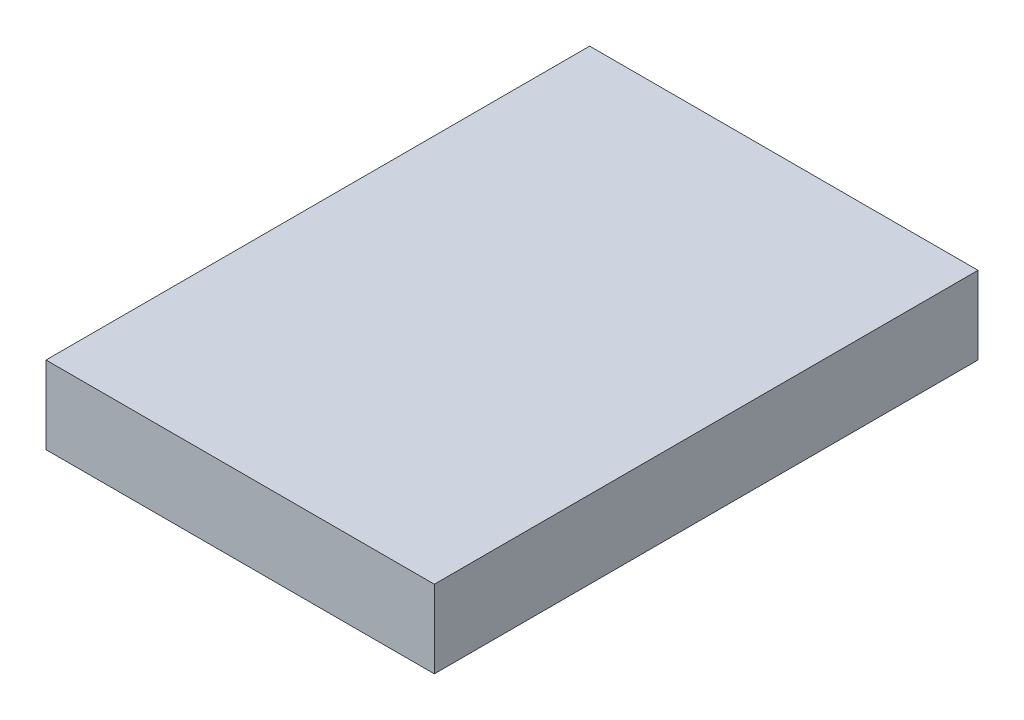
from build123d import *

# Parameters (mm, degrees)
SKETCH1_W           = 25
SKETCH1_H           = 35
BOSS_EXTRUDE1_DEPTH = 5


with BuildPart() as part:
    # Sketch1 → Boss-Extrude1 (new body)
    with BuildSketch(Plane(origin=(0, 0, 0), x_dir=(1, 0, 0), z_dir=(0, 1, 0))):
        Rectangle(SKETCH1_W, SKETCH1_H)
    extrude(amount=BOSS_EXTRUDE1_DEPTH)


solid = part.part
